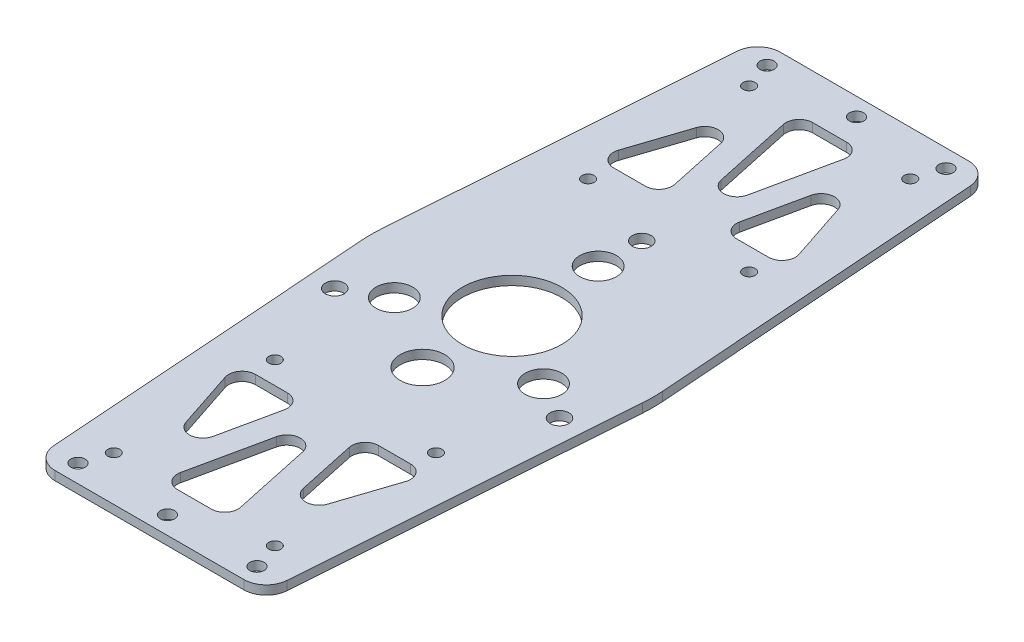
from build123d import *

# Parameters (mm, degrees)
SKETCH_1_W          = 150
SKETCH_1_H          = 180
SKETCH_1_R          = 2.1
EXTRUDE_1_DEPTH     = 2
SKETCH_2_R          = 11.1
SKETCH_2_R_2        = 2.1
SKETCH_2_R_3        = 4.1
SKETCH_2_R_4        = 5
CUT_EXTRUDE_1_DEPTH = 2
SKETCH_3_R          = 1.6
CUT_EXTRUDE_2_DEPTH = 3
SKETCH_4_W          = 150
SKETCH_4_H          = 180
CUT_EXTRUDE_3_DEPTH = 3
FILLET_1_R          = 5
SKETCH_7_R          = 1.35
CUT_EXTRUDE_5_DEPTH = 3
CUT_EXTRUDE_6_DEPTH = 3
FILLET_2_R          = 3


with BuildPart() as part:
    # 草图1 → 凸台-拉伸1 (new body)
    with BuildSketch(Plane(origin=(0, 0, 0), x_dir=(1, 0, 0), z_dir=(0, 1, 0))):
        Rectangle(SKETCH_1_W, SKETCH_1_H)
        with Locations((-70, 85)):
            Circle(SKETCH_1_R, mode=Mode.SUBTRACT)
        with Locations((-50, 85)):
            Circle(SKETCH_1_R, mode=Mode.SUBTRACT)
        with Locations((-50, 65)):
            Circle(SKETCH_1_R, mode=Mode.SUBTRACT)
        with Locations((-70, 65)):
            Circle(SKETCH_1_R, mode=Mode.SUBTRACT)
        with Locations((70, 65)):
            Circle(SKETCH_1_R, mode=Mode.SUBTRACT)
        with Locations((50, 65)):
            Circle(SKETCH_1_R, mode=Mode.SUBTRACT)
        with Locations((50, 85)):
            Circle(SKETCH_1_R, mode=Mode.SUBTRACT)
        with Locations((70, 85)):
            Circle(SKETCH_1_R, mode=Mode.SUBTRACT)
        with Locations((70, -85)):
            Circle(SKETCH_1_R, mode=Mode.SUBTRACT)
        with Locations((50, -85)):
            Circle(SKETCH_1_R, mode=Mode.SUBTRACT)
        with Locations((50, -65)):
            Circle(SKETCH_1_R, mode=Mode.SUBTRACT)
        with Locations((70, -65)):
            Circle(SKETCH_1_R, mode=Mode.SUBTRACT)
        with Locations((-70, -65)):
            Circle(SKETCH_1_R, mode=Mode.SUBTRACT)
        with Locations((-50, -65)):
            Circle(SKETCH_1_R, mode=Mode.SUBTRACT)
        with Locations((-50, -85)):
            Circle(SKETCH_1_R, mode=Mode.SUBTRACT)
        with Locations((-70, -85)):
            Circle(SKETCH_1_R, mode=Mode.SUBTRACT)
    extrude(amount=EXTRUDE_1_DEPTH)

    # 草图2 → 切除-拉伸1 (cut)
    with BuildSketch(Plane(origin=(0, 2, 0), x_dir=(1, 0, 0), z_dir=(0, 1, 0))):
        Circle(SKETCH_2_R)
        with Locations((0, 29)):
            Circle(SKETCH_2_R_2)
        with Locations((25.11473671, -14.5)):
            Circle(SKETCH_2_R_2)
        with Locations((-25.11473671, -14.5)):
            Circle(SKETCH_2_R_2)
        with Locations((0, 19.25)):
            Circle(SKETCH_2_R_3)
        with Locations((16.670989023, -9.625)):
            Circle(SKETCH_2_R_3)
        with Locations((-16.670989023, -9.625)):
            Circle(SKETCH_2_R_3)
        with Locations((0, -20)):
            Circle(SKETCH_2_R_4)
    extrude(amount=-CUT_EXTRUDE_1_DEPTH, mode=Mode.SUBTRACT)

    # 草图3 → 切除-拉伸2 (cut, through all)
    with BuildSketch(Plane(origin=(0, 2, 0), x_dir=(1, 0, 0), z_dir=(0, 1, 0))):
        with Locations((-20, 77)):
            Circle(SKETCH_3_R)
        with Locations((0, 77)):
            Circle(SKETCH_3_R)
        with Locations((20, 77)):
            Circle(SKETCH_3_R)
        with Locations((20, -77)):
            Circle(SKETCH_3_R)
        with Locations((0, -77)):
            Circle(SKETCH_3_R)
        with Locations((-20, -77)):
            Circle(SKETCH_3_R)
    extrude(amount=-CUT_EXTRUDE_2_DEPTH, mode=Mode.SUBTRACT)

    # 草图4 → 切除-拉伸3 (cut, through all)
    with BuildSketch(Plane(origin=(0, 2, 0), x_dir=(1, 0, 0), z_dir=(0, 1, 0))):
        Rectangle(SKETCH_4_W, SKETCH_4_H)
        with BuildLine():
            Line((25.726487009, -81), (-25.726487009, -81))
            Line((-25.726487009, -81), (-31.418007756, -2.271296687))
            ThreePointArc((-31.418007756, -2.271296687), (-31.5, 0), (-31.418007756, 2.271296687))
            Line((-31.418007756, 2.271296687), (-25.726487009, 81))
            Line((-25.726487009, 81), (25.726487009, 81))
            Line((25.726487009, 81), (31.418007756, 2.271296687))
            ThreePointArc((31.418007756, 2.271296687), (31.5, 0), (31.418007756, -2.271296687))
            Line((31.418007756, -2.271296687), (25.726487009, -81))
        make_face(mode=Mode.SUBTRACT)
    extrude(amount=-CUT_EXTRUDE_3_DEPTH, mode=Mode.SUBTRACT)

    # 圆角1
    fillet_1_edges = [part.edges().sort_by_distance(p)[0] for p in [
        (25.726487009, 1, 81),
        (-25.726487009, 1, 81),
        (-25.726487009, 1, -81),
        (25.726487009, 1, -81),
    ]]
    fillet(fillet_1_edges, radius=FILLET_1_R)

    # 草图7 → 切除-拉伸5 (cut, through all)
    with BuildSketch(Plane(origin=(0, 2, 0), x_dir=(1, 0, 0), z_dir=(0, 1, 0))):
        with Locations((-18, 71)):
            Circle(SKETCH_7_R)
        with Locations((18, 71)):
            Circle(SKETCH_7_R)
        with Locations((18, 35)):
            Circle(SKETCH_7_R)
        with Locations((-18, 35)):
            Circle(SKETCH_7_R)
        with Locations((-18, -35)):
            Circle(SKETCH_7_R)
        with Locations((18, -35)):
            Circle(SKETCH_7_R)
        with Locations((18, -71)):
            Circle(SKETCH_7_R)
        with Locations((-18, -71)):
            Circle(SKETCH_7_R)
    extrude(amount=-CUT_EXTRUDE_5_DEPTH, mode=Mode.SUBTRACT)

    # 草图8 → 切除-拉伸6 (cut, through all)
    with BuildSketch(Plane.XZ):
        Polygon((7.5, 71), (-7.5, 71), (0, 36), align=None)
        Polygon((-12.374858275, 67.5), (-21.482001132, 40), (-6.482001132, 40), align=None)
        Polygon((21.482001132, 40), (6.482001132, 40), (12.374858275, 67.5), align=None)
        Polygon((12.374858275, -67.5), (21.482001132, -40), (6.482001132, -40), align=None)
        Polygon((7.5, -71), (-7.5, -71), (0, -36), align=None)
        Polygon((-21.482001132, -40), (-6.482001132, -40), (-12.374858275, -67.5), align=None)
    extrude(amount=-CUT_EXTRUDE_6_DEPTH, mode=Mode.SUBTRACT)

    # 圆角2
    fillet_2_edges = [part.edges().sort_by_distance(p)[0] for p in [
        (-12.374858275, 1, 67.5),
        (-6.482001132, 1, 40),
        (-21.482001132, 1, 40),
        (12.374858275, 1, 67.5),
        (21.482001132, 1, 40),
        (6.482001132, 1, 40),
        (0, 1, -36),
        (7.5, 1, -71),
        (-7.5, 1, -71),
        (12.374858275, 1, -67.5),
        (6.482001132, 1, -40),
        (21.482001132, 1, -40),
        (-12.374858275, 1, -67.5),
        (-21.482001132, 1, -40),
        (-6.482001132, 1, -40),
        (0, 1, 36),
        (-7.5, 1, 71),
        (7.5, 1, 71),
    ]]
    fillet(fillet_2_edges, radius=FILLET_2_R)


solid = part.part
